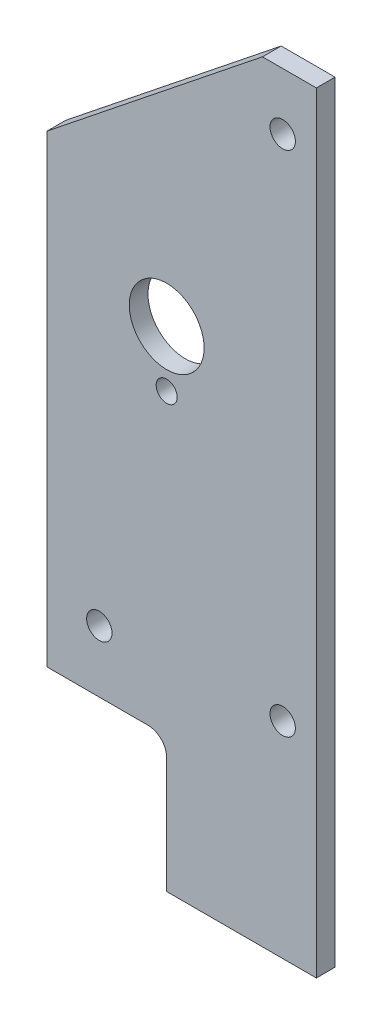
from build123d import *

# Parameters (mm, degrees)
BOSS_EXTRUDE1_DEPTH             = 3.175
F_6_CLEARANCE_HOLE1_D           = 4.3053
F_1_2_0_5_DIAMETER_HOLE1_D      = 12.7
F_9_64_0_14063_DIAMETER_HOLE1_D = 3.572002


with BuildPart() as part:
    # Sketch1 → Boss-Extrude1 (new body)
    with BuildSketch(Plane.XY):
        with BuildLine():
            Line((-25.4, 0), (0, 0))
            Line((0, 0), (0, 130.81))
            Line((0, 130.81), (-9.144, 130.81))
            Line((-9.144, 130.81), (-45.72, 101.6))
            Line((-45.72, 101.6), (-45.72, 22.86))
            Line((-45.72, 22.86), (-28.575, 22.86))
            ThreePointArc((-28.575, 22.86), (-26.32993597, 21.93006403), (-25.4, 19.685))
            Line((-25.4, 19.685), (-25.4, 0))
        make_face()
    extrude(amount=-BOSS_EXTRUDE1_DEPTH)

    # #6 Clearance Hole1 (through all)
    with Locations(Plane.XY):
        with Locations((-5.715, 34.925), (-36.83, 33.3375), (-5.715, 121.158)):
            Hole(F_6_CLEARANCE_HOLE1_D / 2)

    # 1/2 (0.5) Diameter Hole1 (through all)
    with Locations(Plane.XY):
        with Locations((-25.4, 83.058)):
            Hole(F_1_2_0_5_DIAMETER_HOLE1_D / 2)

    # 9/64 (0.14063) Diameter Hole1 (through all)
    with Locations(Plane.XY):
        with Locations((-25.4, 73.533)):
            Hole(F_9_64_0_14063_DIAMETER_HOLE1_D / 2)


solid = part.part
